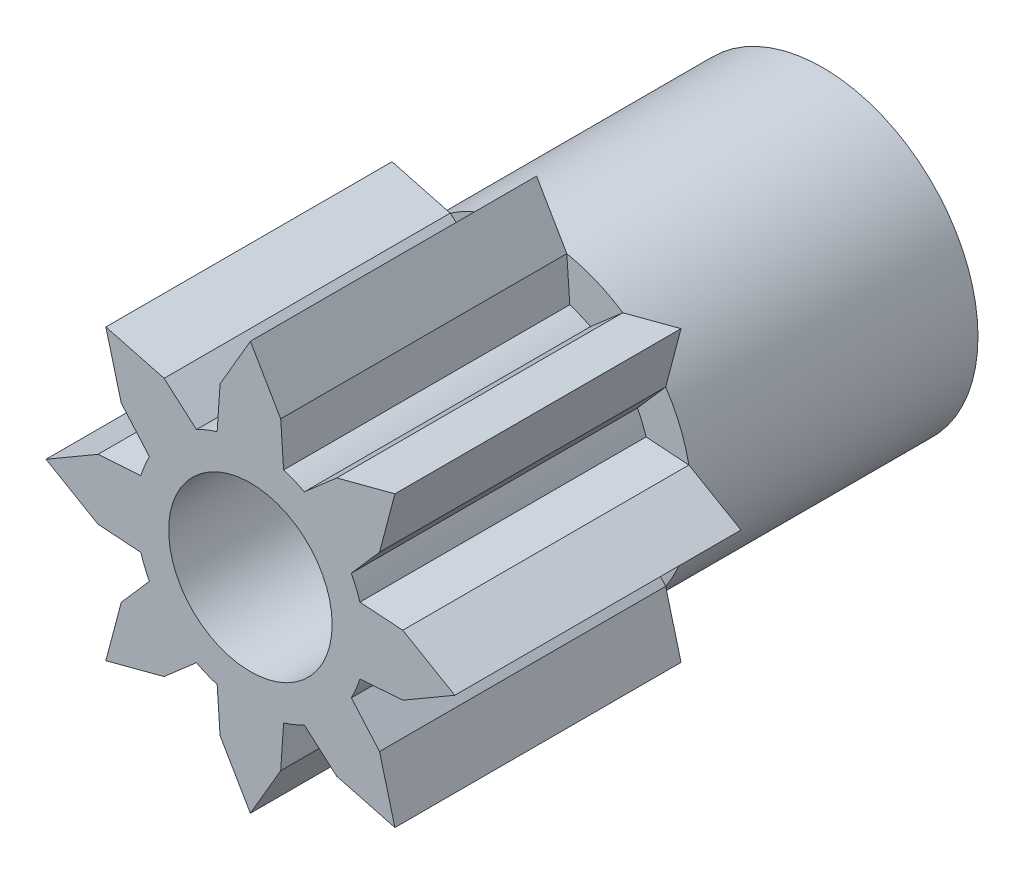
from build123d import *

# Parameters (mm, degrees)
SKETCH1_R           = 1.9
SKETCH1_R_2         = 1
BOSS_EXTRUDE1_DEPTH = 7
SKETCH2_R           = 1.9
SKETCH2_R_2         = 1.4
CUT_EXTRUDE1_DEPTH  = 3.5
SKETCH3_R           = 1
BOSS_EXTRUDE2_DEPTH = 3.5


with BuildPart() as part:
    # Sketch1 → Boss-Extrude1 (new body)
    with BuildSketch(Plane.XY):
        Circle(SKETCH1_R)
        Circle(SKETCH1_R_2, mode=Mode.SUBTRACT)
    extrude(amount=-BOSS_EXTRUDE1_DEPTH)

    # Sketch2 → Cut-Extrude1 (cut)
    with BuildSketch(Plane.XY):
        Circle(SKETCH2_R)
        Circle(SKETCH2_R_2, mode=Mode.SUBTRACT)
    extrude(amount=-CUT_EXTRUDE1_DEPTH, mode=Mode.SUBTRACT)

    # Sketch3 → Boss-Extrude2 (add)
    with BuildSketch(Plane.XY):
        with BuildLine():
            Line((1.579792263, 1.055583443), (1.767766953, 1.767766953))
            Line((1.767766953, 1.767766953), (1.055583443, 1.579792263))
            Line((1.055583443, 1.579792263), (0.659955432, 1.23468977))
            ThreePointArc((0.659955432, 1.23468977), (0.598577131, 1.26558501), (0.535756805, 1.293431346))
            ThreePointArc((0.535756805, 1.293431346), (0.471645795, 1.318161691), (0.406398548, 1.33971647))
            Line((0.406398548, 1.33971647), (0.370671612, 1.863492033))
            Line((0.370671612, 1.863492033), (0, 2.5))
            Line((0, 2.5), (-0.370671612, 1.863492033))
            Line((-0.370671612, 1.863492033), (-0.406398548, 1.33971647))
            ThreePointArc((-0.406398548, 1.33971647), (-0.471645795, 1.318161691), (-0.535756805, 1.293431346))
            ThreePointArc((-0.535756805, 1.293431346), (-0.598577131, 1.26558501), (-0.659955432, 1.23468977))
            Line((-0.659955432, 1.23468977), (-1.055583443, 1.579792263))
            Line((-1.055583443, 1.579792263), (-1.767766953, 1.767766953))
            Line((-1.767766953, 1.767766953), (-1.579792263, 1.055583443))
            Line((-1.579792263, 1.055583443), (-1.23468977, 0.659955432))
            ThreePointArc((-1.23468977, 0.659955432), (-1.26558501, 0.598577131), (-1.293431346, 0.535756805))
            ThreePointArc((-1.293431346, 0.535756805), (-1.318161691, 0.471645795), (-1.33971647, 0.406398548))
            Line((-1.33971647, 0.406398548), (-1.863492033, 0.370671612))
            Line((-1.863492033, 0.370671612), (-2.5, 0))
            Line((-2.5, 0), (-1.863492033, -0.370671612))
            Line((-1.863492033, -0.370671612), (-1.33971647, -0.406398548))
            ThreePointArc((-1.33971647, -0.406398548), (-1.318161691, -0.471645795), (-1.293431346, -0.535756805))
            ThreePointArc((-1.293431346, -0.535756805), (-1.26558501, -0.598577131), (-1.23468977, -0.659955432))
            Line((-1.23468977, -0.659955432), (-1.579792263, -1.055583443))
            Line((-1.579792263, -1.055583443), (-1.767766953, -1.767766953))
            Line((-1.767766953, -1.767766953), (-1.055583443, -1.579792263))
            Line((-1.055583443, -1.579792263), (-0.659955432, -1.23468977))
            ThreePointArc((-0.659955432, -1.23468977), (-0.598577131, -1.26558501), (-0.535756805, -1.293431346))
            ThreePointArc((-0.535756805, -1.293431346), (-0.471645795, -1.318161691), (-0.406398548, -1.33971647))
            Line((-0.406398548, -1.33971647), (-0.370671612, -1.863492033))
            Line((-0.370671612, -1.863492033), (0, -2.5))
            Line((0, -2.5), (0.370671612, -1.863492033))
            Line((0.370671612, -1.863492033), (0.406398548, -1.33971647))
            ThreePointArc((0.406398548, -1.33971647), (0.471645795, -1.318161691), (0.535756805, -1.293431346))
            ThreePointArc((0.535756805, -1.293431346), (0.598577131, -1.26558501), (0.659955432, -1.23468977))
            Line((0.659955432, -1.23468977), (1.055583443, -1.579792263))
            Line((1.055583443, -1.579792263), (1.767766953, -1.767766953))
            Line((1.767766953, -1.767766953), (1.579792263, -1.055583443))
            Line((1.579792263, -1.055583443), (1.23468977, -0.659955432))
            ThreePointArc((1.23468977, -0.659955432), (1.26558501, -0.598577131), (1.293431346, -0.535756805))
            ThreePointArc((1.293431346, -0.535756805), (1.318161691, -0.471645795), (1.33971647, -0.406398548))
            Line((1.33971647, -0.406398548), (1.863492033, -0.370671612))
            Line((1.863492033, -0.370671612), (2.5, 0))
            Line((2.5, 0), (1.863492033, 0.370671612))
            Line((1.863492033, 0.370671612), (1.33971647, 0.406398548))
            ThreePointArc((1.33971647, 0.406398548), (1.318161691, 0.471645795), (1.293431346, 0.535756805))
            ThreePointArc((1.293431346, 0.535756805), (1.26558501, 0.598577131), (1.23468977, 0.659955432))
            Line((1.23468977, 0.659955432), (1.579792263, 1.055583443))
        make_face()
        Circle(SKETCH3_R, mode=Mode.SUBTRACT)
    extrude(amount=-BOSS_EXTRUDE2_DEPTH)


solid = part.part
